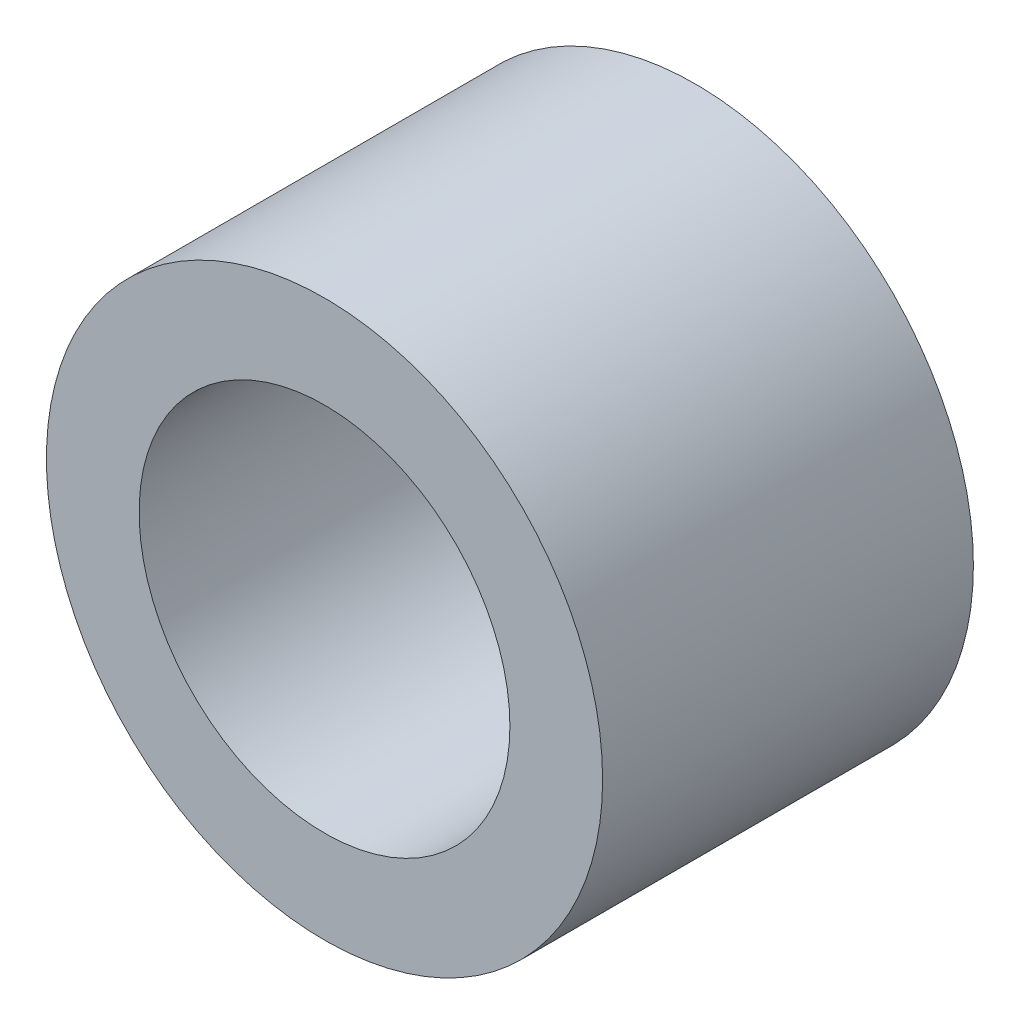
from build123d import *

# Parameters (mm, degrees)
SKETCH1_R           = 4.7625
SKETCH1_R_2         = 3.175
BOSS_EXTRUDE1_DEPTH = 6.35


with BuildPart() as part:
    # Sketch1 → Boss-Extrude1 (new body)
    with BuildSketch(Plane.XY):
        Circle(SKETCH1_R)
        Circle(SKETCH1_R_2, mode=Mode.SUBTRACT)
    extrude(amount=BOSS_EXTRUDE1_DEPTH)


solid = part.part
